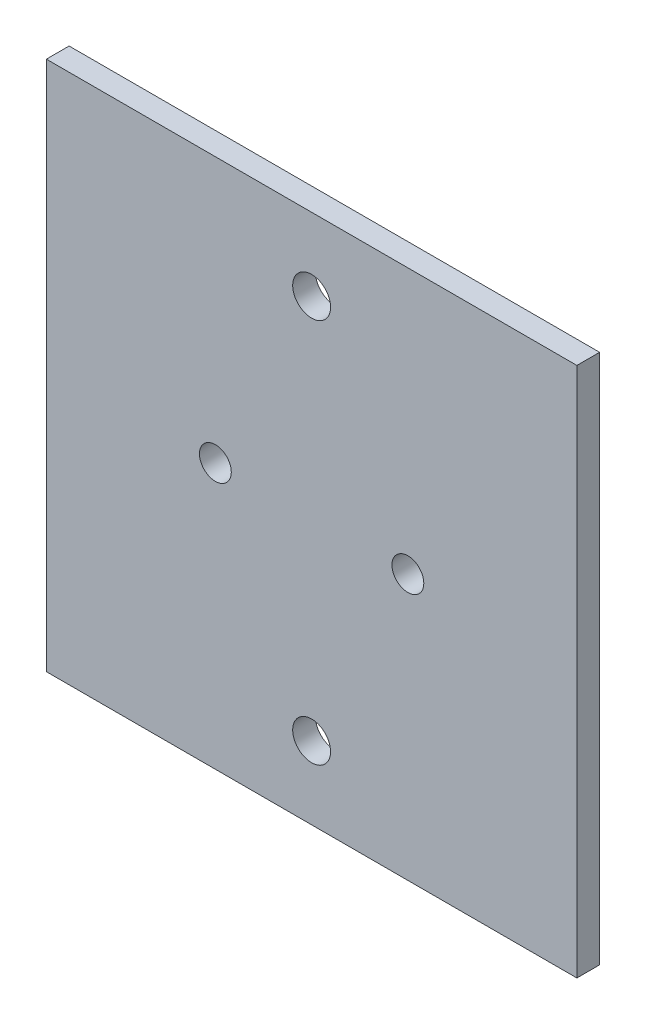
from build123d import *

# Parameters (mm, degrees)
CROQUIS1_W              = 70
CROQUIS1_H              = 70
CROQUIS1_R              = 2.5
SALIENTE_EXTRUIR1_DEPTH = 3
CORTAR_EXTRUIR1_REACH   = 5
CROQUIS2_R              = 2.1


with BuildPart() as part:
    # Croquis1 → Saliente-Extruir1 (new body)
    with BuildSketch(Plane.XY):
        Rectangle(CROQUIS1_W, CROQUIS1_H)
        with Locations((0, 25.4)):
            Circle(CROQUIS1_R, mode=Mode.SUBTRACT)
        with Locations((0, -25.4)):
            Circle(CROQUIS1_R, mode=Mode.SUBTRACT)
    extrude(amount=SALIENTE_EXTRUIR1_DEPTH)

    # Croquis2 → Cortar-Extruir1 (cut, up to next)
    with BuildSketch(Plane.XY.offset(3), mode=Mode.PRIVATE) as cortar_extruir1_sk1:
        with Locations((-12.7, 0)):
            Circle(CROQUIS2_R)
    cortar_extruir1_tool1 = extrude(cortar_extruir1_sk1.sketch, amount=-CORTAR_EXTRUIR1_REACH, mode=Mode.PRIVATE) & part.part
    add(cortar_extruir1_tool1.solids().sort_by_distance((-12.7, 0, 3))[0], mode=Mode.SUBTRACT)
    # Croquis2 → Cortar-Extruir1 (cut, up to next)
    with BuildSketch(Plane.XY.offset(3), mode=Mode.PRIVATE) as cortar_extruir1_sk2:
        with Locations((12.7, 0)):
            Circle(CROQUIS2_R)
    cortar_extruir1_tool2 = extrude(cortar_extruir1_sk2.sketch, amount=-CORTAR_EXTRUIR1_REACH, mode=Mode.PRIVATE) & part.part
    add(cortar_extruir1_tool2.solids().sort_by_distance((12.7, 0, 3))[0], mode=Mode.SUBTRACT)


solid = part.part
